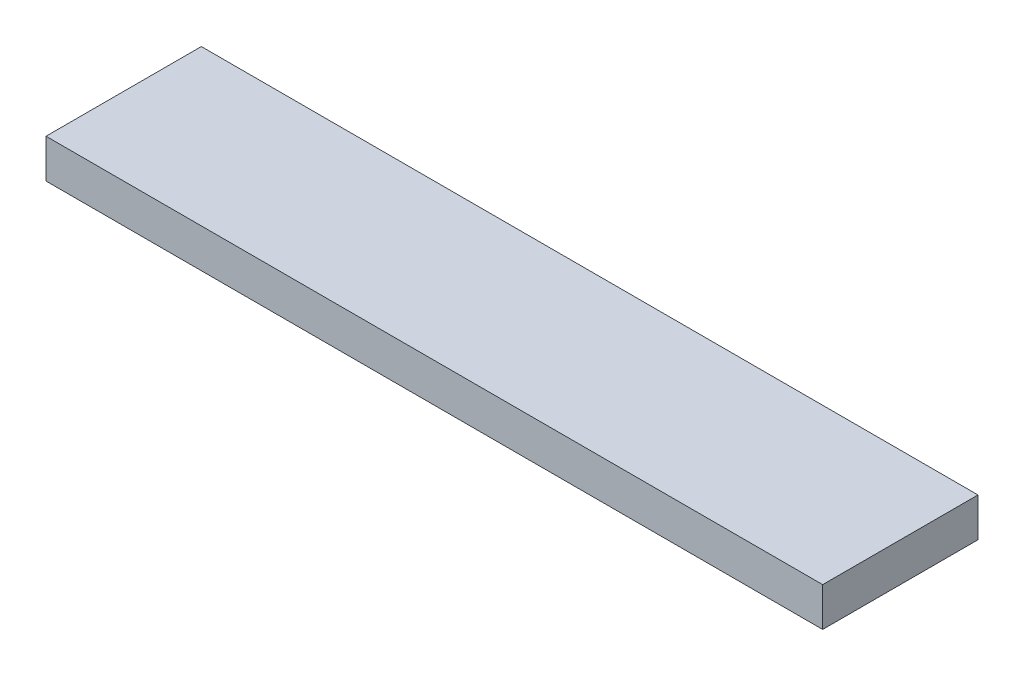
from build123d import *

# Parameters (mm, degrees)
SKETCH_1_W      = 100
SKETCH_1_H      = 20
EXTRUDE_1_DEPTH = 5


with BuildPart() as part:
    # 草图1 → 凸台-拉伸1 (new body)
    with BuildSketch(Plane(origin=(0, 15, 0), x_dir=(1, 0, 0), z_dir=(0, 1, 0))):
        with Locations((26.720720721, -4.31981982)):
            Rectangle(SKETCH_1_W, SKETCH_1_H)
    extrude(amount=EXTRUDE_1_DEPTH)


solid = part.part
